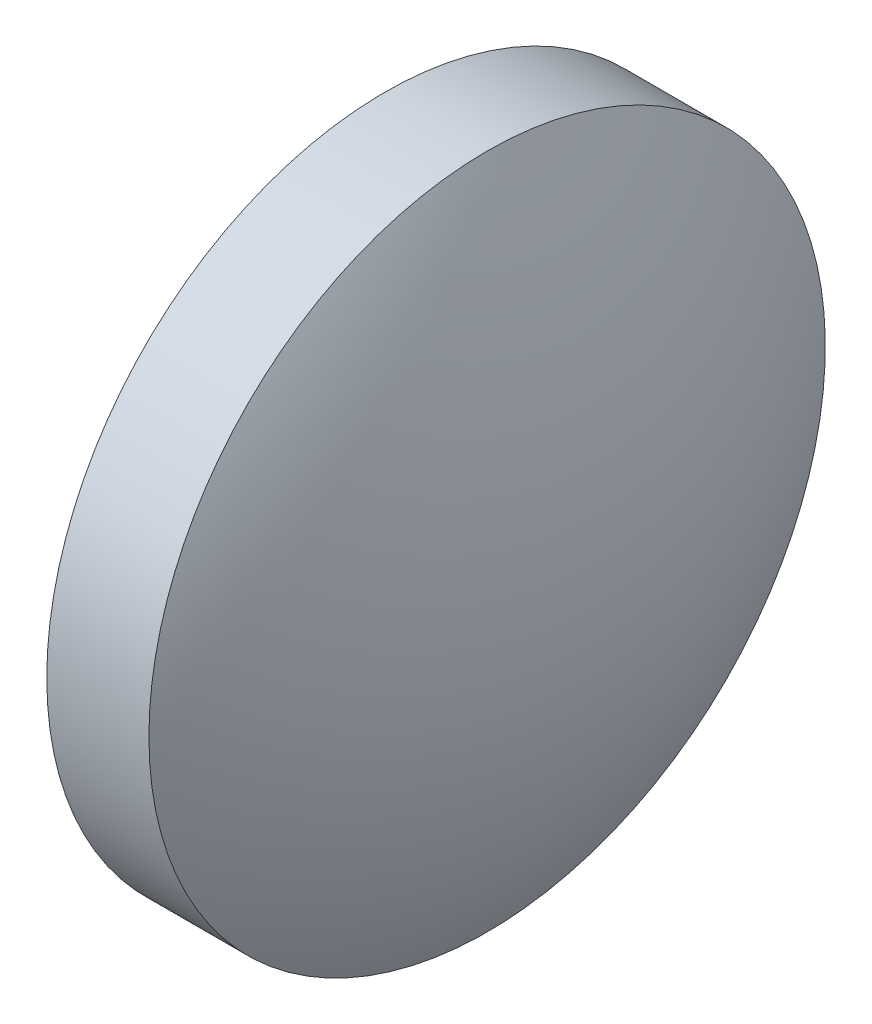
from build123d import *


with BuildPart() as part:
    # 草图1 → 旋转1 (revolve)
    with BuildSketch(Plane.XY):
        with BuildLine():
            Line((650.602002465, 189.562768487), (650.602002465, 194.562768487))
            Line((650.602002465, 194.562768487), (652.112002465, 194.562768487))
            ThreePointArc((652.112002465, 194.562768487), (653.074307257, 192.144633123), (653.402002465, 189.562768487))
            Line((653.402002465, 189.562768487), (650.602002465, 189.562768487))
        make_face()
    revolve(axis=Axis((649.660451993, 189.562768487, 0), (1, 0, 0)))


solid = part.part
